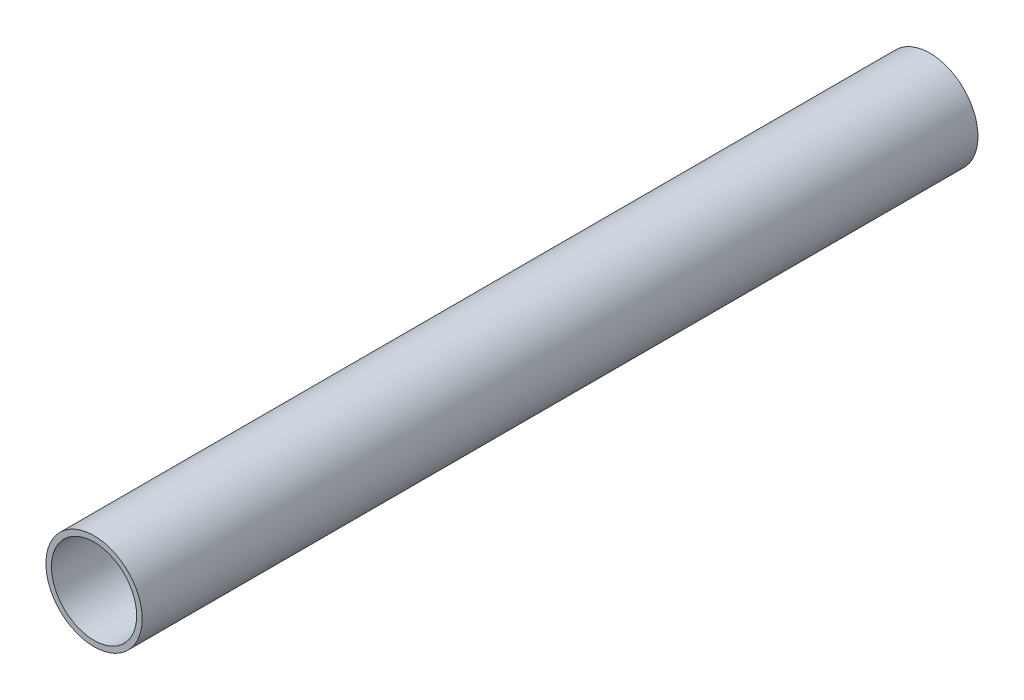
from build123d import *

# Parameters (mm, degrees)
CROQUIS1_R              = 26.2
CROQUIS1_R_2            = 23.2
SALIENTE_EXTRUIR1_DEPTH = 455


with BuildPart() as part:
    # Croquis1 → Saliente-Extruir1 (new body)
    with BuildSketch(Plane.XY):
        Circle(CROQUIS1_R)
        Circle(CROQUIS1_R_2, mode=Mode.SUBTRACT)
    extrude(amount=SALIENTE_EXTRUIR1_DEPTH)


solid = part.part
